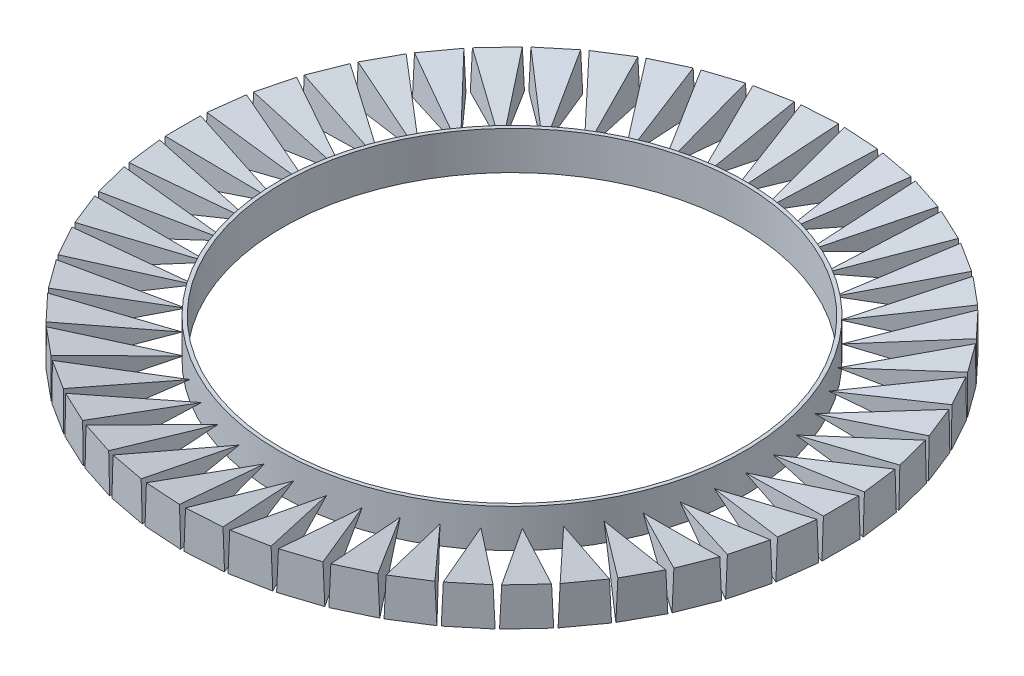
from build123d import *

# Parameters (mm, degrees)
SKETCH1_W           = 10
SKETCH1_H           = 10
BOSS_EXTRUDE1_DEPTH = 25
CUT_EXTRUDE1_DEPTH  = 10
CUT_EXTRUDE2_DEPTH  = 10
CUT_EXTRUDE3_REACH  = 11.806
CUT_EXTRUDE4_REACH  = 11.806
SKETCH7_R           = 60.966426367
SKETCH7_R_2         = 60
BOSS_EXTRUDE4_DEPTH = 10
CIRPATTERN7_COUNT   = 50


with BuildPart() as part:
    # Sketch1 → Boss-Extrude1 (new body)
    with BuildSketch(Plane(origin=(0, 0, 0), x_dir=(0, 0, -1), z_dir=(1, 0, 0))):
        with Locations((5, -5)):
            Rectangle(SKETCH1_W, SKETCH1_H)
    extrude(amount=BOSS_EXTRUDE1_DEPTH)

    # Sketch2 → Cut-Extrude1 (cut)
    with BuildSketch(Plane.XY):
        Polygon((25, -5), (0, 0), (25, 0), align=None)
    extrude(amount=-CUT_EXTRUDE1_DEPTH, mode=Mode.SUBTRACT)

    # Sketch3 → Cut-Extrude2 (cut)
    with BuildSketch(Plane.XY):
        Polygon((25, -5), (0, -10), (25, -10), align=None)
    extrude(amount=-CUT_EXTRUDE2_DEPTH, mode=Mode.SUBTRACT)

    # Cut-Extrude3: up to this face of the body (flat: up to its plane)
    cut_extrude3_end = Plane(part.part.faces().sort_by_distance((12.5, -2.5, -5))[0])
    # Sketch4 → Cut-Extrude3 (cut, up to the picked face)
    with BuildSketch(Plane(origin=(1.923076923, -9.615384615, 0), x_dir=(0.980580676, 0.196116135, 0), z_dir=(0.196116135, -0.980580676, 0)), mode=Mode.PRIVATE) as cut_extrude3_sk1:
        Polygon((23.533936217, -5), (-1.961161351, 0), (23.533936217, 0), align=None)
    cut_extrude3_tool1 = split(extrude(cut_extrude3_sk1.sketch, amount=-CUT_EXTRUDE3_REACH, mode=Mode.PRIVATE), bisect_by=cut_extrude3_end, keep=Keep.BOTH, mode=Mode.PRIVATE)
    add(cut_extrude3_tool1.solids().sort_by_distance((16.666667, -6.666667, -1.666667))[0], mode=Mode.SUBTRACT)

    # Cut-Extrude4: up to this face of the body (flat: up to its plane)
    cut_extrude4_end = Plane(part.part.faces().sort_by_distance((11.184210526, -2.236842105, -6.224696356))[0])
    # Sketch5 → Cut-Extrude4 (cut, up to the picked face)
    with BuildSketch(Plane(origin=(1.923076923, -9.615384615, 0), x_dir=(0.980580676, 0.196116135, 0), z_dir=(0.196116135, -0.980580676, 0)), mode=Mode.PRIVATE) as cut_extrude4_sk1:
        Polygon((23.533936217, -5), (-1.961161351, -10), (23.533936217, -10), align=None)
    cut_extrude4_tool1 = split(extrude(cut_extrude4_sk1.sketch, amount=-CUT_EXTRUDE4_REACH, mode=Mode.PRIVATE), bisect_by=cut_extrude4_end, keep=Keep.BOTH, mode=Mode.PRIVATE)
    add(cut_extrude4_tool1.solids().sort_by_distance((16.666667, -6.666667, -8.333333))[0], mode=Mode.SUBTRACT)


with BuildPart() as body_2:
    # Sketch7 → Boss-Extrude4 (new body)
    with BuildSketch(Plane(origin=(0, 0, 0), x_dir=(1, 0, 0), z_dir=(0, 1, 0))):
        with Locations((85.966426367, 5)):
            Circle(SKETCH7_R)
        with Locations((85.966426367, 5)):
            Circle(SKETCH7_R_2, mode=Mode.SUBTRACT)
    extrude(amount=-BOSS_EXTRUDE4_DEPTH)


with BuildPart() as cirpattern7_1:
    # CirPattern7: pattern copy
    add(part.part.rotate(Axis((85.966426367, 0, -5), (0, 1, 0)), 1 * 360 / CIRPATTERN7_COUNT))


with BuildPart() as cirpattern7_2:
    # CirPattern7: pattern copy
    add(part.part.rotate(Axis((85.966426367, 0, -5), (0, 1, 0)), 2 * 360 / CIRPATTERN7_COUNT))


with BuildPart() as cirpattern7_3:
    # CirPattern7: pattern copy
    add(part.part.rotate(Axis((85.966426367, 0, -5), (0, 1, 0)), 3 * 360 / CIRPATTERN7_COUNT))


with BuildPart() as cirpattern7_4:
    # CirPattern7: pattern copy
    add(part.part.rotate(Axis((85.966426367, 0, -5), (0, 1, 0)), 4 * 360 / CIRPATTERN7_COUNT))


with BuildPart() as cirpattern7_5:
    # CirPattern7: pattern copy
    add(part.part.rotate(Axis((85.966426367, 0, -5), (0, 1, 0)), 5 * 360 / CIRPATTERN7_COUNT))


with BuildPart() as cirpattern7_6:
    # CirPattern7: pattern copy
    add(part.part.rotate(Axis((85.966426367, 0, -5), (0, 1, 0)), 6 * 360 / CIRPATTERN7_COUNT))


with BuildPart() as cirpattern7_7:
    # CirPattern7: pattern copy
    add(part.part.rotate(Axis((85.966426367, 0, -5), (0, 1, 0)), 7 * 360 / CIRPATTERN7_COUNT))


with BuildPart() as cirpattern7_8:
    # CirPattern7: pattern copy
    add(part.part.rotate(Axis((85.966426367, 0, -5), (0, 1, 0)), 8 * 360 / CIRPATTERN7_COUNT))


with BuildPart() as cirpattern7_9:
    # CirPattern7: pattern copy
    add(part.part.rotate(Axis((85.966426367, 0, -5), (0, 1, 0)), 9 * 360 / CIRPATTERN7_COUNT))


with BuildPart() as cirpattern7_10:
    # CirPattern7: pattern copy
    add(part.part.rotate(Axis((85.966426367, 0, -5), (0, 1, 0)), 10 * 360 / CIRPATTERN7_COUNT))


with BuildPart() as cirpattern7_11:
    # CirPattern7: pattern copy
    add(part.part.rotate(Axis((85.966426367, 0, -5), (0, 1, 0)), 11 * 360 / CIRPATTERN7_COUNT))


with BuildPart() as cirpattern7_12:
    # CirPattern7: pattern copy
    add(part.part.rotate(Axis((85.966426367, 0, -5), (0, 1, 0)), 12 * 360 / CIRPATTERN7_COUNT))


with BuildPart() as cirpattern7_13:
    # CirPattern7: pattern copy
    add(part.part.rotate(Axis((85.966426367, 0, -5), (0, 1, 0)), 13 * 360 / CIRPATTERN7_COUNT))


with BuildPart() as cirpattern7_14:
    # CirPattern7: pattern copy
    add(part.part.rotate(Axis((85.966426367, 0, -5), (0, 1, 0)), 14 * 360 / CIRPATTERN7_COUNT))


with BuildPart() as cirpattern7_15:
    # CirPattern7: pattern copy
    add(part.part.rotate(Axis((85.966426367, 0, -5), (0, 1, 0)), 15 * 360 / CIRPATTERN7_COUNT))


with BuildPart() as cirpattern7_16:
    # CirPattern7: pattern copy
    add(part.part.rotate(Axis((85.966426367, 0, -5), (0, 1, 0)), 16 * 360 / CIRPATTERN7_COUNT))


with BuildPart() as cirpattern7_17:
    # CirPattern7: pattern copy
    add(part.part.rotate(Axis((85.966426367, 0, -5), (0, 1, 0)), 17 * 360 / CIRPATTERN7_COUNT))


with BuildPart() as cirpattern7_18:
    # CirPattern7: pattern copy
    add(part.part.rotate(Axis((85.966426367, 0, -5), (0, 1, 0)), 18 * 360 / CIRPATTERN7_COUNT))


with BuildPart() as cirpattern7_19:
    # CirPattern7: pattern copy
    add(part.part.rotate(Axis((85.966426367, 0, -5), (0, 1, 0)), 19 * 360 / CIRPATTERN7_COUNT))


with BuildPart() as cirpattern7_20:
    # CirPattern7: pattern copy
    add(part.part.rotate(Axis((85.966426367, 0, -5), (0, 1, 0)), 20 * 360 / CIRPATTERN7_COUNT))


with BuildPart() as cirpattern7_21:
    # CirPattern7: pattern copy
    add(part.part.rotate(Axis((85.966426367, 0, -5), (0, 1, 0)), 21 * 360 / CIRPATTERN7_COUNT))


with BuildPart() as cirpattern7_22:
    # CirPattern7: pattern copy
    add(part.part.rotate(Axis((85.966426367, 0, -5), (0, 1, 0)), 22 * 360 / CIRPATTERN7_COUNT))


with BuildPart() as cirpattern7_23:
    # CirPattern7: pattern copy
    add(part.part.rotate(Axis((85.966426367, 0, -5), (0, 1, 0)), 23 * 360 / CIRPATTERN7_COUNT))


with BuildPart() as cirpattern7_24:
    # CirPattern7: pattern copy
    add(part.part.rotate(Axis((85.966426367, 0, -5), (0, 1, 0)), 24 * 360 / CIRPATTERN7_COUNT))


with BuildPart() as cirpattern7_25:
    # CirPattern7: pattern copy
    add(part.part.rotate(Axis((85.966426367, 0, -5), (0, 1, 0)), 25 * 360 / CIRPATTERN7_COUNT))


with BuildPart() as cirpattern7_26:
    # CirPattern7: pattern copy
    add(part.part.rotate(Axis((85.966426367, 0, -5), (0, 1, 0)), 26 * 360 / CIRPATTERN7_COUNT))


with BuildPart() as cirpattern7_27:
    # CirPattern7: pattern copy
    add(part.part.rotate(Axis((85.966426367, 0, -5), (0, 1, 0)), 27 * 360 / CIRPATTERN7_COUNT))


with BuildPart() as cirpattern7_28:
    # CirPattern7: pattern copy
    add(part.part.rotate(Axis((85.966426367, 0, -5), (0, 1, 0)), 28 * 360 / CIRPATTERN7_COUNT))


with BuildPart() as cirpattern7_29:
    # CirPattern7: pattern copy
    add(part.part.rotate(Axis((85.966426367, 0, -5), (0, 1, 0)), 29 * 360 / CIRPATTERN7_COUNT))


with BuildPart() as cirpattern7_30:
    # CirPattern7: pattern copy
    add(part.part.rotate(Axis((85.966426367, 0, -5), (0, 1, 0)), 30 * 360 / CIRPATTERN7_COUNT))


with BuildPart() as cirpattern7_31:
    # CirPattern7: pattern copy
    add(part.part.rotate(Axis((85.966426367, 0, -5), (0, 1, 0)), 31 * 360 / CIRPATTERN7_COUNT))


with BuildPart() as cirpattern7_32:
    # CirPattern7: pattern copy
    add(part.part.rotate(Axis((85.966426367, 0, -5), (0, 1, 0)), 32 * 360 / CIRPATTERN7_COUNT))


with BuildPart() as cirpattern7_33:
    # CirPattern7: pattern copy
    add(part.part.rotate(Axis((85.966426367, 0, -5), (0, 1, 0)), 33 * 360 / CIRPATTERN7_COUNT))


with BuildPart() as cirpattern7_34:
    # CirPattern7: pattern copy
    add(part.part.rotate(Axis((85.966426367, 0, -5), (0, 1, 0)), 34 * 360 / CIRPATTERN7_COUNT))


with BuildPart() as cirpattern7_35:
    # CirPattern7: pattern copy
    add(part.part.rotate(Axis((85.966426367, 0, -5), (0, 1, 0)), 35 * 360 / CIRPATTERN7_COUNT))


with BuildPart() as cirpattern7_36:
    # CirPattern7: pattern copy
    add(part.part.rotate(Axis((85.966426367, 0, -5), (0, 1, 0)), 36 * 360 / CIRPATTERN7_COUNT))


with BuildPart() as cirpattern7_37:
    # CirPattern7: pattern copy
    add(part.part.rotate(Axis((85.966426367, 0, -5), (0, 1, 0)), 37 * 360 / CIRPATTERN7_COUNT))


with BuildPart() as cirpattern7_38:
    # CirPattern7: pattern copy
    add(part.part.rotate(Axis((85.966426367, 0, -5), (0, 1, 0)), 38 * 360 / CIRPATTERN7_COUNT))


with BuildPart() as cirpattern7_39:
    # CirPattern7: pattern copy
    add(part.part.rotate(Axis((85.966426367, 0, -5), (0, 1, 0)), 39 * 360 / CIRPATTERN7_COUNT))


with BuildPart() as cirpattern7_40:
    # CirPattern7: pattern copy
    add(part.part.rotate(Axis((85.966426367, 0, -5), (0, 1, 0)), 40 * 360 / CIRPATTERN7_COUNT))


with BuildPart() as cirpattern7_41:
    # CirPattern7: pattern copy
    add(part.part.rotate(Axis((85.966426367, 0, -5), (0, 1, 0)), 41 * 360 / CIRPATTERN7_COUNT))


with BuildPart() as cirpattern7_42:
    # CirPattern7: pattern copy
    add(part.part.rotate(Axis((85.966426367, 0, -5), (0, 1, 0)), 42 * 360 / CIRPATTERN7_COUNT))


with BuildPart() as cirpattern7_43:
    # CirPattern7: pattern copy
    add(part.part.rotate(Axis((85.966426367, 0, -5), (0, 1, 0)), 43 * 360 / CIRPATTERN7_COUNT))


with BuildPart() as cirpattern7_44:
    # CirPattern7: pattern copy
    add(part.part.rotate(Axis((85.966426367, 0, -5), (0, 1, 0)), 44 * 360 / CIRPATTERN7_COUNT))


with BuildPart() as cirpattern7_45:
    # CirPattern7: pattern copy
    add(part.part.rotate(Axis((85.966426367, 0, -5), (0, 1, 0)), 45 * 360 / CIRPATTERN7_COUNT))


with BuildPart() as cirpattern7_46:
    # CirPattern7: pattern copy
    add(part.part.rotate(Axis((85.966426367, 0, -5), (0, 1, 0)), 46 * 360 / CIRPATTERN7_COUNT))


with BuildPart() as cirpattern7_47:
    # CirPattern7: pattern copy
    add(part.part.rotate(Axis((85.966426367, 0, -5), (0, 1, 0)), 47 * 360 / CIRPATTERN7_COUNT))


with BuildPart() as cirpattern7_48:
    # CirPattern7: pattern copy
    add(part.part.rotate(Axis((85.966426367, 0, -5), (0, 1, 0)), 48 * 360 / CIRPATTERN7_COUNT))


with BuildPart() as cirpattern7_49:
    # CirPattern7: pattern copy
    add(part.part.rotate(Axis((85.966426367, 0, -5), (0, 1, 0)), 49 * 360 / CIRPATTERN7_COUNT))


solid = Compound([part.part, body_2.part, cirpattern7_1.part, cirpattern7_2.part, cirpattern7_3.part, cirpattern7_4.part, cirpattern7_5.part, cirpattern7_6.part, cirpattern7_7.part, cirpattern7_8.part, cirpattern7_9.part, cirpattern7_10.part, cirpattern7_11.part, cirpattern7_12.part, cirpattern7_13.part, cirpattern7_14.part, cirpattern7_15.part, cirpattern7_16.part, cirpattern7_17.part, cirpattern7_18.part, cirpattern7_19.part, cirpattern7_20.part, cirpattern7_21.part, cirpattern7_22.part, cirpattern7_23.part, cirpattern7_24.part, cirpattern7_25.part, cirpattern7_26.part, cirpattern7_27.part, cirpattern7_28.part, cirpattern7_29.part, cirpattern7_30.part, cirpattern7_31.part, cirpattern7_32.part, cirpattern7_33.part, cirpattern7_34.part, cirpattern7_35.part, cirpattern7_36.part, cirpattern7_37.part, cirpattern7_38.part, cirpattern7_39.part, cirpattern7_40.part, cirpattern7_41.part, cirpattern7_42.part, cirpattern7_43.part, cirpattern7_44.part, cirpattern7_45.part, cirpattern7_46.part, cirpattern7_47.part, cirpattern7_48.part, cirpattern7_49.part])
